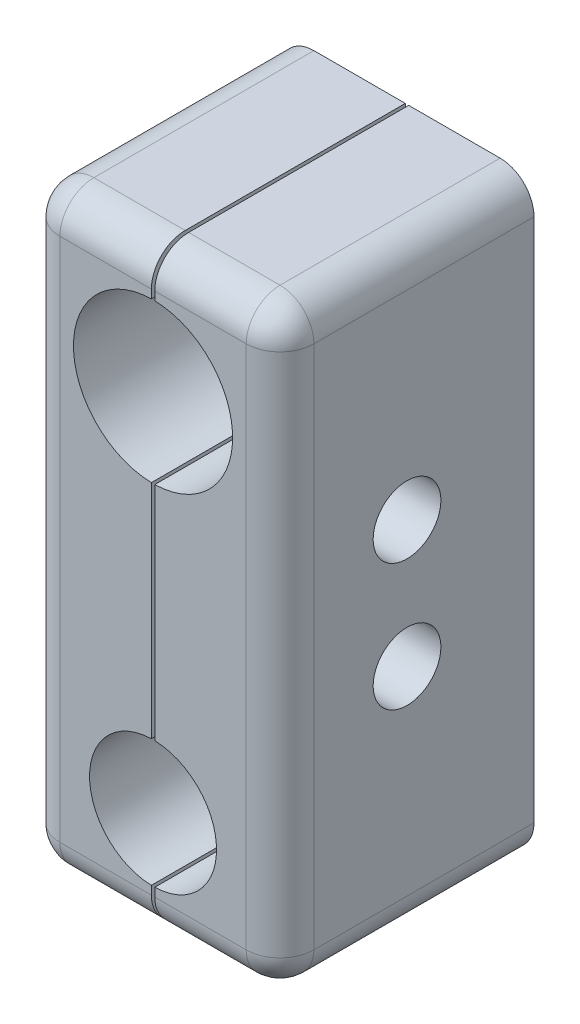
from build123d import *

# Parameters (mm, degrees)
SKETCH1_W           = 19.05
SKETCH1_H           = 44.45
BOSS_EXTRUDE1_DEPTH = 19.05
CUT_EXTRUDE1_REACH  = 21.05
SKETCH2_R           = 5.969
SKETCH2_R_2         = 4.7625
CUT_EXTRUDE2_REACH  = 21.05
SKETCH3_R           = 1.5875
SKETCH6_R           = 2.54
CUT_EXTRUDE5_DEPTH  = 3.81
CUT_EXTRUDE3_DEPTH  = 3.96875
FILLET1_R           = 2.54
CUT_EXTRUDE4_START  = -19.05
SKETCH5_W           = 0.254
SKETCH5_H           = 44.45
CUT_EXTRUDE4_DEPTH  = 19.05


with BuildPart() as part:
    # Sketch1 → Boss-Extrude1 (new body)
    with BuildSketch(Plane.XY):
        Rectangle(SKETCH1_W, SKETCH1_H)
    extrude(amount=BOSS_EXTRUDE1_DEPTH)

    # Sketch2 → Cut-Extrude1 (cut, up to next)
    with BuildSketch(Plane.XY.offset(19.05), mode=Mode.PRIVATE) as cut_extrude1_sk1:
        with Locations((0, 13.081)):
            Circle(SKETCH2_R)
    cut_extrude1_tool1 = extrude(cut_extrude1_sk1.sketch, amount=-CUT_EXTRUDE1_REACH, mode=Mode.PRIVATE) & part.part
    add(cut_extrude1_tool1.solids().sort_by_distance((0, 13.081, 19.05))[0], mode=Mode.SUBTRACT)
    # Sketch2 → Cut-Extrude1 (cut, up to next)
    with BuildSketch(Plane.XY.offset(19.05), mode=Mode.PRIVATE) as cut_extrude1_sk2:
        with Locations((0, -14.2875)):
            Circle(SKETCH2_R_2)
    cut_extrude1_tool2 = extrude(cut_extrude1_sk2.sketch, amount=-CUT_EXTRUDE1_REACH, mode=Mode.PRIVATE) & part.part
    add(cut_extrude1_tool2.solids().sort_by_distance((0, -14.2875, 19.05))[0], mode=Mode.SUBTRACT)

    # Sketch3 → Cut-Extrude2 (cut, up to next)
    with BuildSketch(Plane(origin=(9.525, 0, 0), x_dir=(0, 0, -1), z_dir=(1, 0, 0)), mode=Mode.PRIVATE) as cut_extrude2_sk1:
        with Locations((-9.525, -4.7625)):
            Circle(SKETCH3_R)
    cut_extrude2_tool1 = extrude(cut_extrude2_sk1.sketch, amount=-CUT_EXTRUDE2_REACH, mode=Mode.PRIVATE) & part.part
    add(cut_extrude2_tool1.solids().sort_by_distance((9.525, -4.7625, 9.525))[0], mode=Mode.SUBTRACT)
    # Sketch3 → Cut-Extrude2 (cut, up to next)
    with BuildSketch(Plane(origin=(9.525, 0, 0), x_dir=(0, 0, -1), z_dir=(1, 0, 0)), mode=Mode.PRIVATE) as cut_extrude2_sk2:
        with Locations((-9.525, 4.7625)):
            Circle(SKETCH3_R)
    cut_extrude2_tool2 = extrude(cut_extrude2_sk2.sketch, amount=-CUT_EXTRUDE2_REACH, mode=Mode.PRIVATE) & part.part
    add(cut_extrude2_tool2.solids().sort_by_distance((9.525, 4.7625, 9.525))[0], mode=Mode.SUBTRACT)

    # Sketch6 → Cut-Extrude5 (cut)
    with BuildSketch(Plane(origin=(9.525, 0, 0), x_dir=(0, 0, -1), z_dir=(1, 0, 0))):
        with Locations((-9.525, -4.7625)):
            Circle(SKETCH6_R)
        with Locations((-9.525, 4.7625)):
            Circle(SKETCH6_R)
    extrude(amount=-CUT_EXTRUDE5_DEPTH, mode=Mode.SUBTRACT)

    # Sketch4 → Cut-Extrude3 (cut)
    with BuildSketch(Plane.ZY.offset(9.525)):
        Polygon((9.525, 1.023002306), (12.7635, 2.892751153), (12.7635, 6.632248847), (9.525, 8.501997694), (6.2865, 6.632248847), (6.2865, 2.892751153), align=None)
        Polygon((9.525, -8.501997694), (12.7635, -6.632248847), (12.7635, -2.892751153), (9.525, -1.023002306), (6.2865, -2.892751153), (6.2865, -6.632248847), align=None)
    extrude(amount=-CUT_EXTRUDE3_DEPTH, mode=Mode.SUBTRACT)

    # Fillet1
    fillet1_edges = [part.edges().sort_by_distance(p)[0] for p in [
        (9.525, 0, 19.05),
        (0, 22.225, 19.05),
        (-9.525, 0, 19.05),
        (0, -22.225, 19.05),
        (-9.525, 22.225, 9.525),
        (9.525, 22.225, 9.525),
        (9.525, -22.225, 9.525),
        (-9.525, -22.225, 9.525),
    ]]
    fillet(fillet1_edges, radius=FILLET1_R)

    # Sketch5 → Cut-Extrude4 (cut)
    with BuildSketch(Plane(origin=(0, 0, 0), x_dir=(-1, 0, 0), z_dir=(0, 0, -1)).offset(CUT_EXTRUDE4_START)):
        Rectangle(SKETCH5_W, SKETCH5_H)
    extrude(amount=CUT_EXTRUDE4_DEPTH, mode=Mode.SUBTRACT)


solid = part.part
